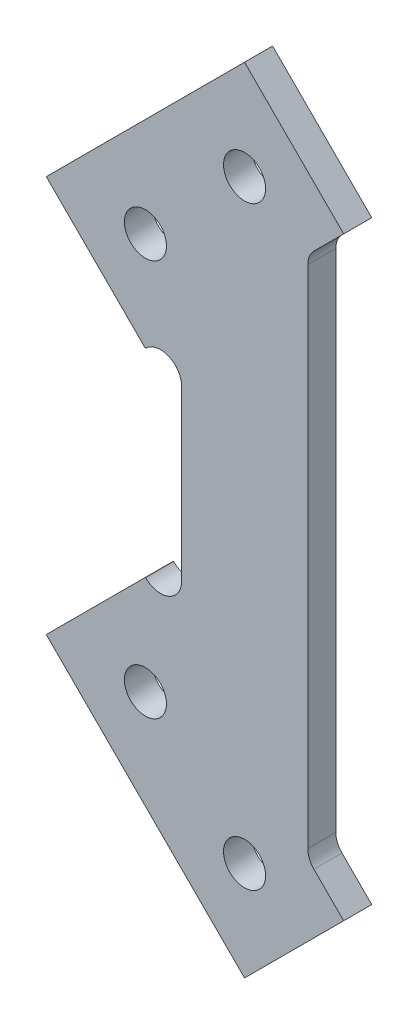
from build123d import *

# Parameters (mm, degrees)
SKETCH1_R           = 3
BOSS_EXTRUDE1_DEPTH = 4


with BuildPart() as part:
    # Sketch1 → Boss-Extrude1 (new body)
    with BuildSketch(Plane.XY):
        with BuildLine():
            Line((-14.162950904, 14.142135624), (-14.121320344, 14.183766184))
            ThreePointArc((-14.121320344, 14.183766184), (-10.851949703, 14.834084438), (-9, 12.062445841))
            Line((-9, 12.062445841), (-9, -12.062445841))
            ThreePointArc((-9, -12.062445841), (-10.851949703, -14.834084438), (-14.121320344, -14.183766184))
            Line((-14.121320344, -14.183766184), (-14.162950904, -14.142135624))
            Line((-14.162950904, -14.142135624), (-28.305086528, -28.284271247))
            Line((-28.305086528, -28.284271247), (-0.02081528, -56.568542495))
            Line((-0.02081528, -56.568542495), (14.121320344, -42.426406871))
            Line((14.121320344, -42.426406871), (9.878679656, -38.183766184))
            ThreePointArc((9.878679656, -38.183766184), (9.228361402, -37.210496138), (9, -36.062445841))
            Line((9, -36.062445841), (9, 36.062445841))
            ThreePointArc((9, 36.062445841), (9.228361402, 37.210496138), (9.878679656, 38.183766184))
            Line((9.878679656, 38.183766184), (14.121320344, 42.426406871))
            Line((14.121320344, 42.426406871), (-0.02081528, 56.568542495))
            Line((-0.02081528, 56.568542495), (-28.305086528, 28.284271247))
            Line((-28.305086528, 28.284271247), (-14.162950904, 14.142135624))
        make_face()
        with Locations((-0.02081528, 42.426406871)):
            Circle(SKETCH1_R, mode=Mode.SUBTRACT)
        with Locations((-14.162950904, 28.284271247)):
            Circle(SKETCH1_R, mode=Mode.SUBTRACT)
        with Locations((-14.162950904, -28.284271247)):
            Circle(SKETCH1_R, mode=Mode.SUBTRACT)
        with Locations((-0.02081528, -42.426406871)):
            Circle(SKETCH1_R, mode=Mode.SUBTRACT)
    extrude(amount=BOSS_EXTRUDE1_DEPTH)


solid = part.part
